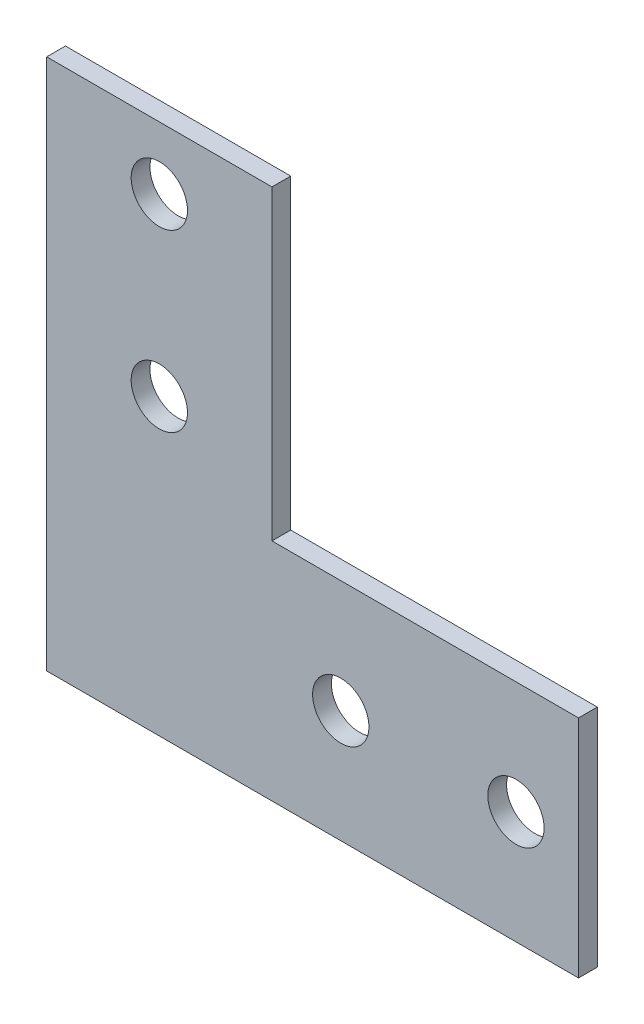
from build123d import *

# Parameters (mm, degrees)
SKETCH_1_R      = 4.5
EXTRUDE_1_DEPTH = 3


with BuildPart() as part:
    # Эскиз1 → Бобышка-Вытянуть1 (new body)
    with BuildSketch(Plane.XY):
        Polygon((0, 85), (0, 0), (85, 0), (85, 36), (36, 36), (36, 85), align=None)
        with Locations((18, 75)):
            Circle(SKETCH_1_R, mode=Mode.SUBTRACT)
        with Locations((18, 47)):
            Circle(SKETCH_1_R, mode=Mode.SUBTRACT)
        with Locations((47, 18)):
            Circle(SKETCH_1_R, mode=Mode.SUBTRACT)
        with Locations((75, 18)):
            Circle(SKETCH_1_R, mode=Mode.SUBTRACT)
    extrude(amount=EXTRUDE_1_DEPTH)


solid = part.part
